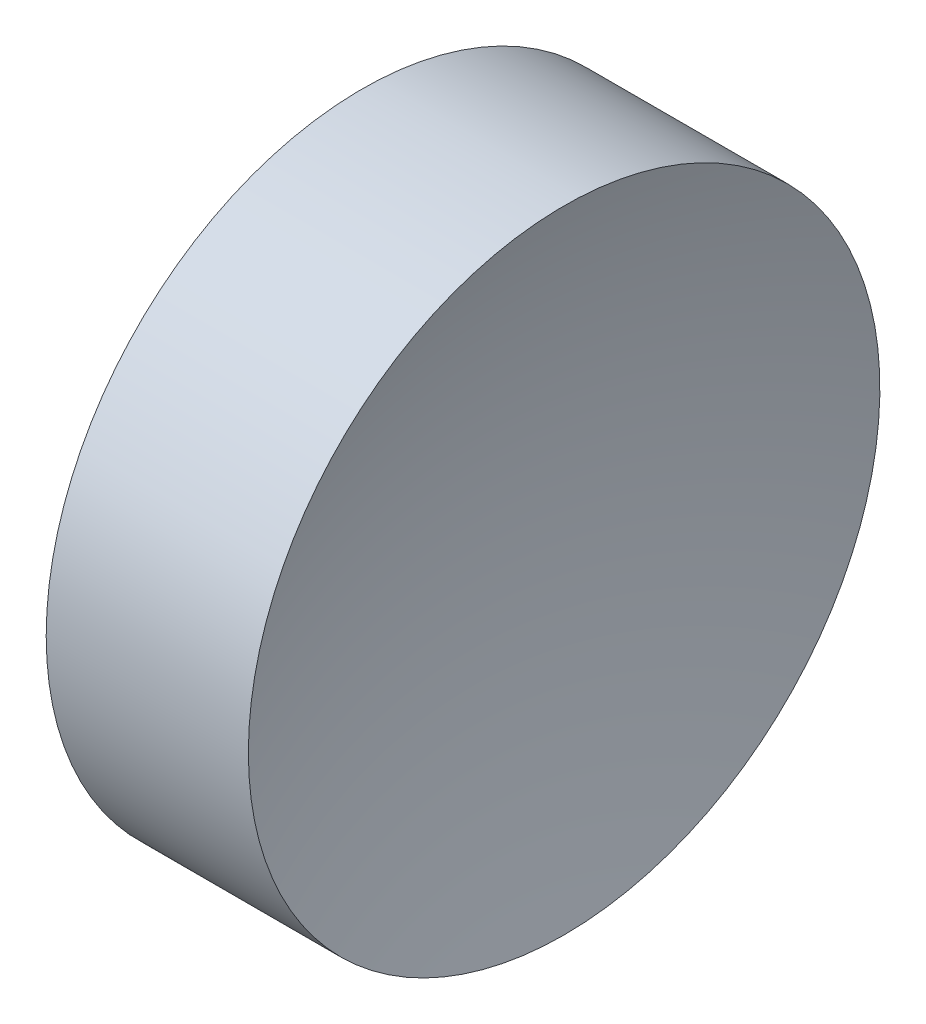
from build123d import *


with BuildPart() as part:
    # 草图1 → 旋转1 (revolve)
    with BuildSketch(Plane.XY, mode=Mode.PRIVATE) as revolve_1_sk:
        with BuildLine():
            Line((57.546327767, 34.689010562), (57.546327767, 40.939010562))
            Line((57.546327767, 40.939010562), (61.547972565, 40.939010562))
            ThreePointArc((61.547972565, 40.939010562), (60.798326543, 37.853887823), (60.546327756, 34.689010562))
            Line((60.546327756, 34.689010562), (57.546327767, 34.689010562))
        make_face()
    revolve(revolve_1_sk.sketch.rotate(Axis((54.492571501, 34.689010562, 0), (1, 0, 0)), 180), axis=Axis((54.492571501, 34.689010562, 0), (1, 0, 0)))  # turned: the seam where the file's is


solid = part.part
